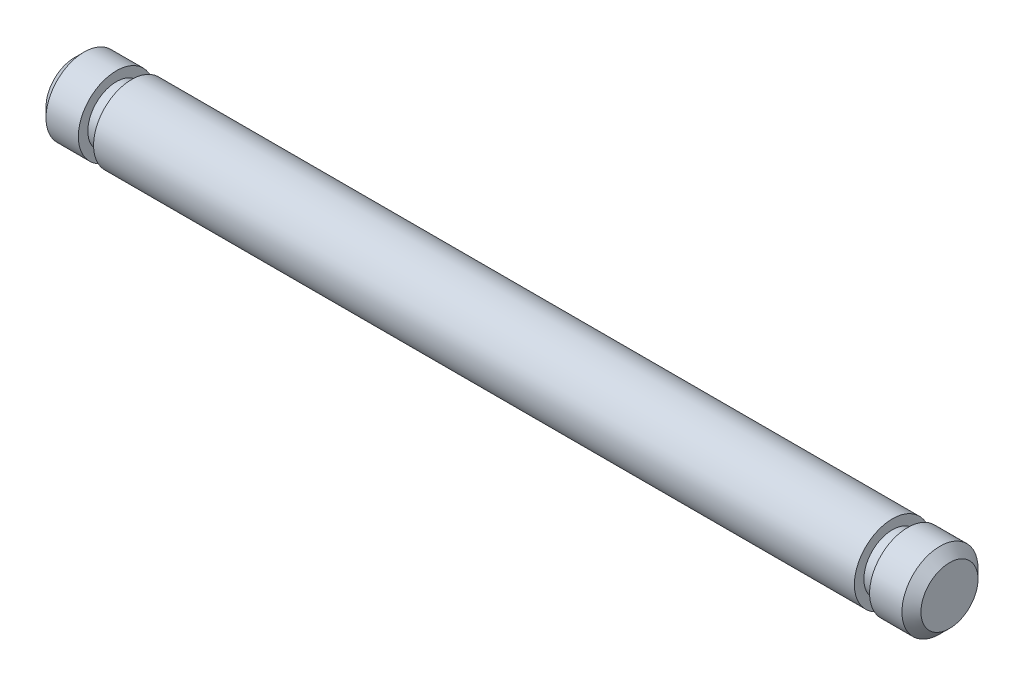
from build123d import *

# Parameters (mm, degrees)
SKETCH1_R           = 2
BOSS_EXTRUDE1_DEPTH = 46
CHAMFER1_SIZE       = 0.5
CUT_EXTRUDE1_START  = -3
SKETCH2_R           = 2
SKETCH2_R_2         = 1.5
CUT_EXTRUDE1_DEPTH  = 0.8
CUT_EXTRUDE2_START  = -3
SKETCH3_R           = 2
SKETCH3_R_2         = 1.5
CUT_EXTRUDE2_DEPTH  = 0.8


with BuildPart() as part:
    # Sketch1 → Boss-Extrude1 (new body)
    with BuildSketch(Plane(origin=(0, 0, 0), x_dir=(0, 0, -1), z_dir=(1, 0, 0))):
        Circle(SKETCH1_R)
    extrude(amount=BOSS_EXTRUDE1_DEPTH)

    # Chamfer1
    chamfer1_edges = [part.edges().sort_by_distance(p)[0] for p in [
        (0, 0, 2),
        (46, 0, 2),
    ]]
    chamfer(chamfer1_edges, length=CHAMFER1_SIZE)

    # Sketch2 → Cut-Extrude1 (cut)
    with BuildSketch(Plane(origin=(46, 0, 0), x_dir=(0, 0, -1), z_dir=(1, 0, 0)).offset(CUT_EXTRUDE1_START)):
        Circle(SKETCH2_R)
        Circle(SKETCH2_R_2, mode=Mode.SUBTRACT)
    extrude(amount=CUT_EXTRUDE1_DEPTH, mode=Mode.SUBTRACT)

    # Sketch3 → Cut-Extrude2 (cut)
    with BuildSketch(Plane.ZY.offset(CUT_EXTRUDE2_START)):
        Circle(SKETCH3_R)
        Circle(SKETCH3_R_2, mode=Mode.SUBTRACT)
    extrude(amount=CUT_EXTRUDE2_DEPTH, mode=Mode.SUBTRACT)


solid = part.part
